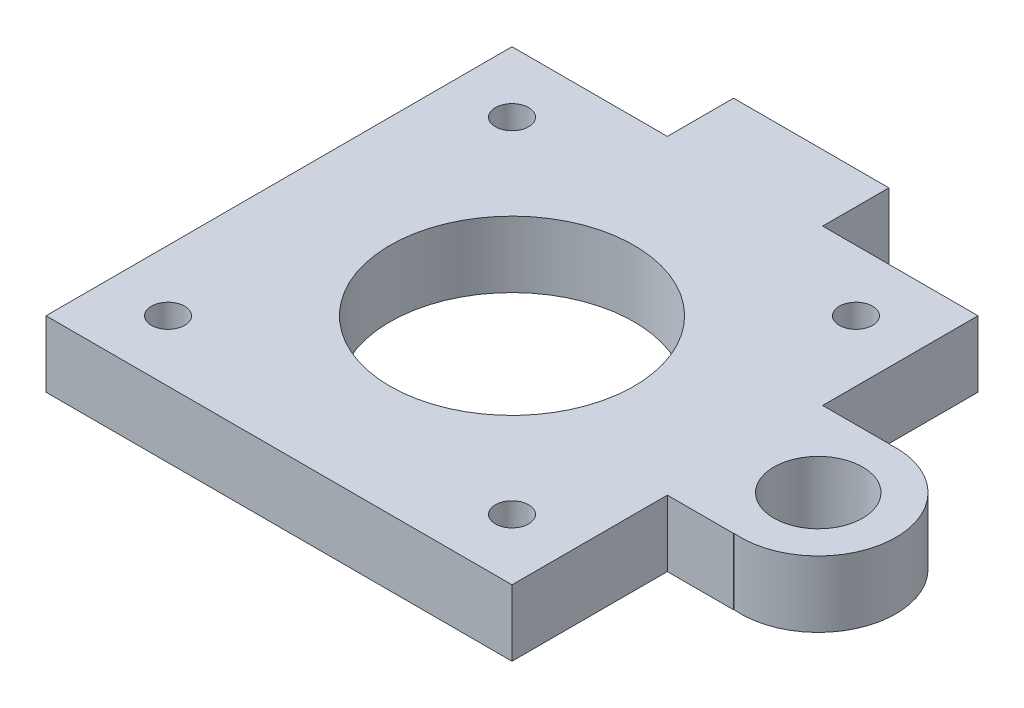
from build123d import *

# Parameters (mm, degrees)
SKETCH1_W           = 42
SKETCH1_H           = 42
SKETCH1_R           = 11
SKETCH1_R_2         = 1.5
BOSS_EXTRUDE1_DEPTH = 5.969
SKETCH2_W           = 14
SKETCH2_H           = 5.969
SKETCH2_W_2         = 5.969
SKETCH2_H_2         = 14
BOSS_EXTRUDE2_DEPTH = 5.969
SKETCH4_R           = 7
BOSS_EXTRUDE5_DEPTH = 5.969
SKETCH6_R           = 4
CUT_EXTRUDE2_DEPTH  = 6.35


with BuildPart() as part:
    # Sketch1 → Boss-Extrude1 (new body)
    with BuildSketch(Plane(origin=(0, 0, 0), x_dir=(1, 0, 0), z_dir=(0, 1, 0))):
        with Locations((21, 21)):
            Rectangle(SKETCH1_W, SKETCH1_H)
        with Locations((21, 21)):
            Circle(SKETCH1_R, mode=Mode.SUBTRACT)
        with Locations((5.5, 36.5)):
            Circle(SKETCH1_R_2, mode=Mode.SUBTRACT)
        with Locations((36.5, 36.5)):
            Circle(SKETCH1_R_2, mode=Mode.SUBTRACT)
        with Locations((36.5, 5.5)):
            Circle(SKETCH1_R_2, mode=Mode.SUBTRACT)
        with Locations((5.5, 5.5)):
            Circle(SKETCH1_R_2, mode=Mode.SUBTRACT)
    extrude(amount=BOSS_EXTRUDE1_DEPTH)

    # Sketch2 → Boss-Extrude2 (add)
    with BuildSketch(Plane(origin=(0, 5.969, 0), x_dir=(1, 0, 0), z_dir=(0, 1, 0))):
        with Locations((21, 44.9845)):
            Rectangle(SKETCH2_W, SKETCH2_H)
        with Locations((44.9845, 21)):
            Rectangle(SKETCH2_W_2, SKETCH2_H_2)
    extrude(amount=-BOSS_EXTRUDE2_DEPTH)

    # Sketch4 → Boss-Extrude5 (add)
    with BuildSketch(Plane(origin=(0, 5.969, 0), x_dir=(1, 0, 0), z_dir=(0, 1, 0))):
        with Locations((48.6039, 21)):
            Circle(SKETCH4_R)
    extrude(amount=-BOSS_EXTRUDE5_DEPTH)

    # Sketch6 → Cut-Extrude2 (cut)
    with BuildSketch(Plane(origin=(0, 5.969, 0), x_dir=(1, 0, 0), z_dir=(0, 1, 0))):
        with Locations((48.6039, 21)):
            Circle(SKETCH6_R)
    extrude(amount=-CUT_EXTRUDE2_DEPTH, mode=Mode.SUBTRACT)


solid = part.part
